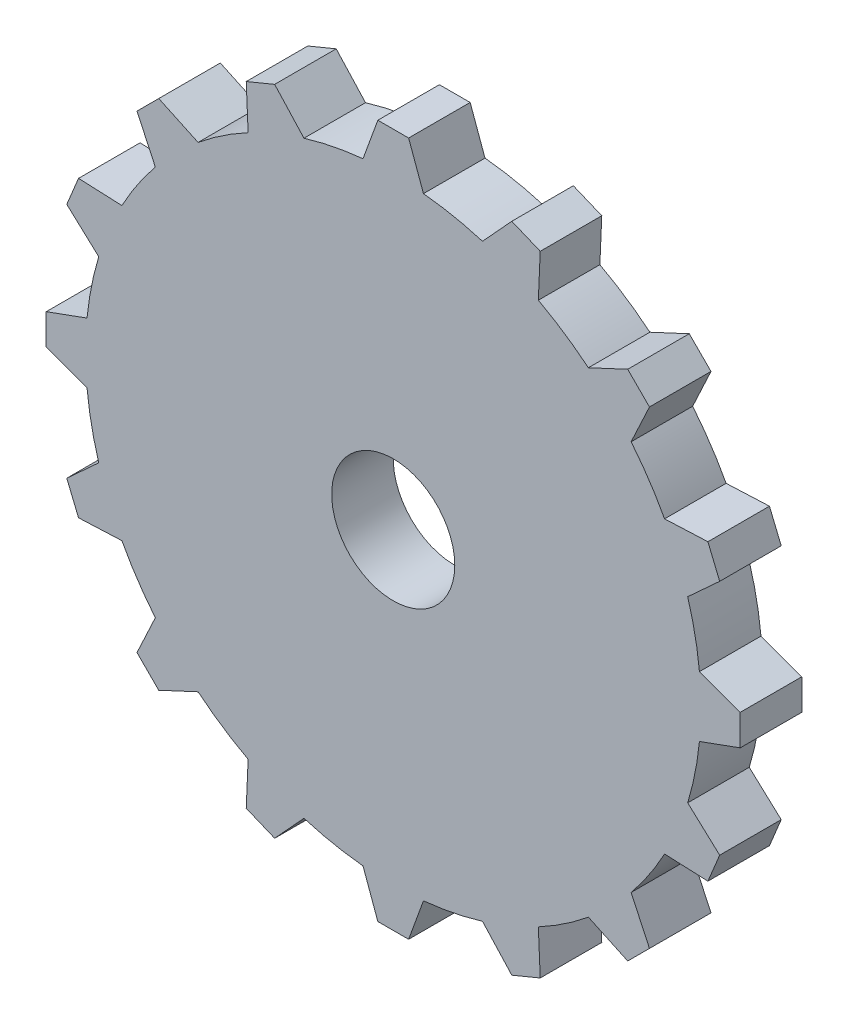
from build123d import *

# Parameters (mm, degrees)
SKETCH2_R           = 1
BOSS_EXTRUDE2_DEPTH = 1


with BuildPart() as part:
    # Sketch2 → Boss-Extrude2 (new body)
    with BuildSketch(Plane.XY):
        with BuildLine():
            Line((-0.25, 5.638363295), (0.25, 5.638363295))
            Line((0.25, 5.638363295), (0.491146384, 4.975819051))
            ThreePointArc((0.491146384, 4.975819051), (0.97545161, 4.903926402), (1.450403422, 4.785010963))
            Line((1.450403422, 4.785010963), (1.926738336, 5.304839303))
            Line((1.926738336, 5.304839303), (2.388678102, 5.113497587))
            Line((2.388678102, 5.113497587), (2.357923605, 4.409103795))
            ThreePointArc((2.357923605, 4.409103795), (2.777851165, 4.157348062), (3.171142455, 3.865728332))
            Line((3.171142455, 3.865728332), (3.810148226, 4.163701616))
            Line((3.810148226, 4.163701616), (4.163701616, 3.810148226))
            Line((4.163701616, 3.810148226), (3.865728332, 3.171142455))
            ThreePointArc((3.865728332, 3.171142455), (4.157348062, 2.777851165), (4.409103795, 2.357923605))
            Line((4.409103795, 2.357923605), (5.113497587, 2.388678102))
            Line((5.113497587, 2.388678102), (5.304839303, 1.926738336))
            Line((5.304839303, 1.926738336), (4.785010963, 1.450403422))
            ThreePointArc((4.785010963, 1.450403422), (4.903926402, 0.97545161), (4.975819051, 0.491146384))
            Line((4.975819051, 0.491146384), (5.638363295, 0.25))
            Line((5.638363295, 0.25), (5.638363295, -0.25))
            Line((5.638363295, -0.25), (4.975819051, -0.491146384))
            ThreePointArc((4.975819051, -0.491146384), (4.903926402, -0.97545161), (4.785010963, -1.450403422))
            Line((4.785010963, -1.450403422), (5.304839303, -1.926738336))
            Line((5.304839303, -1.926738336), (5.113497587, -2.388678102))
            Line((5.113497587, -2.388678102), (4.409103795, -2.357923605))
            ThreePointArc((4.409103795, -2.357923605), (4.157348062, -2.777851165), (3.865728332, -3.171142455))
            Line((3.865728332, -3.171142455), (4.163701616, -3.810148226))
            Line((4.163701616, -3.810148226), (3.810148226, -4.163701616))
            Line((3.810148226, -4.163701616), (3.171142455, -3.865728332))
            ThreePointArc((3.171142455, -3.865728332), (2.777851165, -4.157348062), (2.357923605, -4.409103795))
            Line((2.357923605, -4.409103795), (2.388678102, -5.113497587))
            Line((2.388678102, -5.113497587), (1.926738336, -5.304839303))
            Line((1.926738336, -5.304839303), (1.450403422, -4.785010963))
            ThreePointArc((1.450403422, -4.785010963), (0.97545161, -4.903926402), (0.491146384, -4.975819051))
            Line((0.491146384, -4.975819051), (0.25, -5.638363295))
            Line((0.25, -5.638363295), (-0.25, -5.638363295))
            Line((-0.25, -5.638363295), (-0.491146384, -4.975819051))
            ThreePointArc((-0.491146384, -4.975819051), (-0.97545161, -4.903926402), (-1.450403422, -4.785010963))
            Line((-1.450403422, -4.785010963), (-1.926738336, -5.304839303))
            Line((-1.926738336, -5.304839303), (-2.388678102, -5.113497587))
            Line((-2.388678102, -5.113497587), (-2.357923605, -4.409103795))
            ThreePointArc((-2.357923605, -4.409103795), (-2.777851165, -4.157348062), (-3.171142455, -3.865728332))
            Line((-3.171142455, -3.865728332), (-3.810148226, -4.163701616))
            Line((-3.810148226, -4.163701616), (-4.163701616, -3.810148226))
            Line((-4.163701616, -3.810148226), (-3.865728332, -3.171142455))
            ThreePointArc((-3.865728332, -3.171142455), (-4.157348062, -2.777851165), (-4.409103795, -2.357923605))
            Line((-4.409103795, -2.357923605), (-5.113497587, -2.388678102))
            Line((-5.113497587, -2.388678102), (-5.304839303, -1.926738336))
            Line((-5.304839303, -1.926738336), (-4.785010963, -1.450403422))
            ThreePointArc((-4.785010963, -1.450403422), (-4.903926402, -0.97545161), (-4.975819051, -0.491146384))
            Line((-4.975819051, -0.491146384), (-5.638363295, -0.25))
            Line((-5.638363295, -0.25), (-5.638363295, 0.25))
            Line((-5.638363295, 0.25), (-4.975819051, 0.491146384))
            ThreePointArc((-4.975819051, 0.491146384), (-4.903926402, 0.97545161), (-4.785010963, 1.450403422))
            Line((-4.785010963, 1.450403422), (-5.304839303, 1.926738336))
            Line((-5.304839303, 1.926738336), (-5.113497587, 2.388678102))
            Line((-5.113497587, 2.388678102), (-4.409103795, 2.357923605))
            ThreePointArc((-4.409103795, 2.357923605), (-4.157348062, 2.777851165), (-3.865728332, 3.171142455))
            Line((-3.865728332, 3.171142455), (-4.163701616, 3.810148226))
            Line((-4.163701616, 3.810148226), (-3.810148226, 4.163701616))
            Line((-3.810148226, 4.163701616), (-3.171142455, 3.865728332))
            ThreePointArc((-3.171142455, 3.865728332), (-2.777851165, 4.157348062), (-2.357923605, 4.409103795))
            Line((-2.357923605, 4.409103795), (-2.388678102, 5.113497587))
            Line((-2.388678102, 5.113497587), (-1.926738336, 5.304839303))
            Line((-1.926738336, 5.304839303), (-1.450403422, 4.785010963))
            ThreePointArc((-1.450403422, 4.785010963), (-0.97545161, 4.903926402), (-0.491146384, 4.975819051))
            Line((-0.491146384, 4.975819051), (-0.25, 5.638363295))
        make_face()
        Circle(SKETCH2_R, mode=Mode.SUBTRACT)
    extrude(amount=BOSS_EXTRUDE2_DEPTH)


solid = part.part
